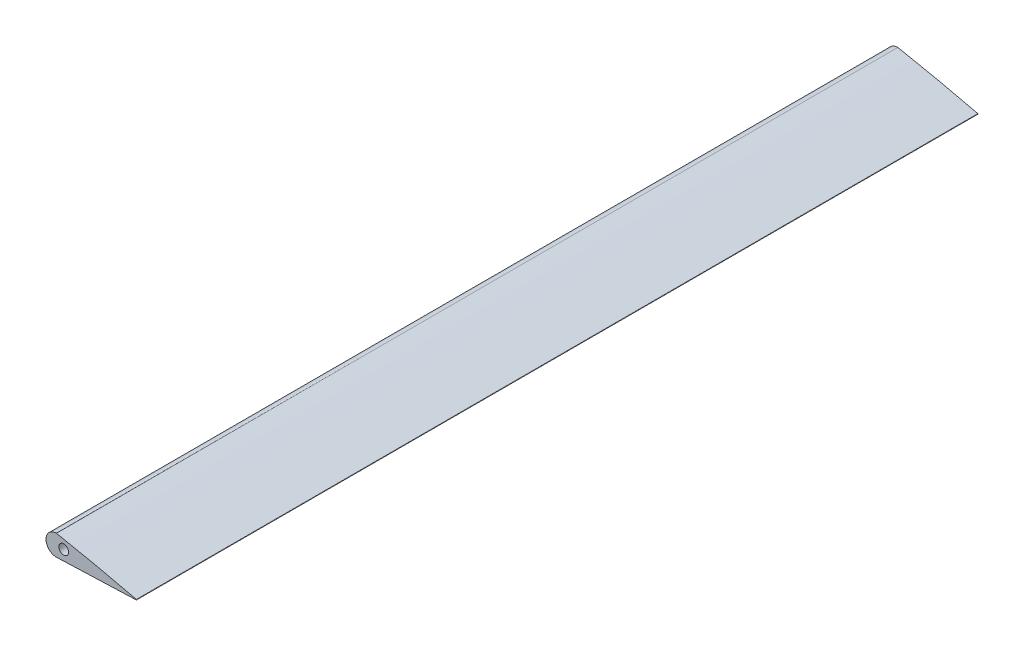
from build123d import *

# Parameters (mm, degrees)
BOSS_EXTRUDE1_DEPTH     = 1246.6
SKETCH3_W               = 131.331770321
SKETCH3_H               = 32.627886165
CUT_EXTRUDE1_DEPTH      = 1246.6
SKETCH4_OUTSIDE_W       = 284.212
SKETCH4_OUTSIDE_H       = 1498.012
SKETCH4_OUTSIDE_W_2     = 101.260819251
SKETCH4_OUTSIDE_H_2     = 902.35
CUT_EXTRUDE2_DEPTH      = 1246.6
CUT_EXTRUDE2_DEPTH_BACK = 1246.6
SKETCH6_W               = 192.425220297
SKETCH6_H               = 656.595980709
CUT_EXTRUDE4_DEPTH      = 244.6
CUT_EXTRUDE4_DEPTH_BACK = 244.6
BOSS_EXTRUDE2_DEPTH     = 344.25
SKETCH8_R               = 2
CUT_EXTRUDE5_DEPTH      = 440.25
BOSS_EXTRUDE3_DEPTH     = 344.25


with BuildPart() as part:
    # Sketch2 → Boss-Extrude1 (new body)
    with BuildSketch(Plane.XY):
        with BuildLine():
            ThreePointArc((164, 0.098236), (164.077666621, 0), (164, -0.098236))
            add(Edge.make_bspline(
                [(164, 0.098236), (163.453347387, 0.22785535), (162.360115672, 0.487076621), (160.720174081, 0.874802791), (159.0803353, 1.261113511), (156.894331896, 1.771896592), (154.161962419, 2.401008024), (150.881840501, 3.13752569), (147.601664878, 3.8565945), (144.321701501, 4.559852267), (141.041699291, 5.246218097), (137.76175682, 5.915571977), (134.481686048, 6.566534279), (131.201761117, 7.199897784), (127.921667908, 7.813753566), (124.641700877, 8.409171836), (121.361597548, 8.984649762), (118.081600921, 9.541284352), (114.80156054, 10.07805903), (111.521600724, 10.59503458), (108.241713881, 11.090964684), (104.961715387, 11.562926189), (101.681785545, 12.010166942), (98.401746925, 12.429708933), (95.121663003, 12.820499879), (91.84154242, 13.181831195), (88.56141358, 13.513629691), (85.281283013, 13.815893693), (82.001169218, 14.088694548), (78.721094583, 14.331740841), (75.441021202, 14.543174526), (72.160894943, 14.719912929), (68.880725837, 14.859427859), (65.600502918, 14.959161187), (62.320224888, 15.016118491), (59.039990485, 15.033011113), (55.759814901, 15.012803506), (52.479681447, 14.959633887), (49.199602023, 14.875645385), (45.919233047, 14.766824698), (42.638537604, 14.618826672), (39.35741618, 14.416022628), (36.0757975, 14.141603361), (32.793533639, 13.779735578), (29.511749086, 13.311848817), (26.230434788, 12.73694115), (22.948210639, 12.059086716), (19.663974378, 11.271431309), (16.378115428, 10.351737997), (13.092739035, 9.271649911), (10.358155698, 8.239855905), (8.178743414, 7.269152702), (6.527119207, 6.423628718), (4.860632605, 5.419014553), (3.322167842, 4.2467282), (2.166779904, 3.134218531), (1.284843627, 2.240038349), (0.724778476, 1.586326252), (0.356487216, 1.023714566), (0.176338644, 0.655158851), (0.06126114, 0.337632955), (-0.042912187, -0.121140297), (0.010077209, -0.598533271), (0.176198668, -1.014077877), (0.354673422, -1.344525075), (0.71711018, -1.826240306), (1.269772602, -2.336774849), (2.131753938, -2.920204414), (3.354944478, -3.392789107), (4.915318485, -3.707166706), (6.554156477, -4.033049695), (8.195338778, -4.283515671), (10.382269573, -4.515400478), (13.118624925, -4.672653042), (16.398857973, -4.828475576), (19.67949402, -4.922126922), (22.959843945, -4.966534444), (26.240094921, -4.967885333), (29.52021808, -4.932840584), (32.80025799, -4.868949356), (36.080251417, -4.782671539), (39.360205991, -4.679002025), (42.640130231, -4.562992137), (45.920050783, -4.439945198), (49.199963424, -4.314095857), (52.479955348, -4.190748674), (55.759981202, -4.070022155), (59.039983191, -3.950079723), (62.320004382, -3.831269928), (65.600009186, -3.712064205), (68.88000861, -3.592327441), (72.160010289, -3.472160061), (75.439998328, -3.351294551), (78.720004422, -3.230701442), (81.999996044, -3.109715239), (85.279997332, -2.98904612), (88.559996558, -2.868484945), (91.840000392, -2.748158688), (95.119999867, -2.627768375), (98.40000014, -2.507399813), (101.679999573, -2.387008373), (104.960003573, -2.266686622), (108.24000017, -2.146108622), (111.519995748, -2.025502888), (114.800004809, -1.905264268), (118.079995042, -1.784567671), (121.360004998, -1.664353418), (124.639994992, -1.543650291), (127.920005011, -1.423437787), (131.199994988, -1.302734192), (134.480005012, -1.182521815), (137.759994988, -1.061818182), (141.040005013, -0.941605825), (144.319994986, -0.820902151), (147.600005017, -0.70068994), (150.879994971, -0.579985719), (154.160005076, -0.45977555), (156.893330138, -0.359182339), (159.080000325, -0.278972842), (160.719999512, -0.218762724), (162.360003633, -0.15863219), (163.453333876, -0.118368088), (164, -0.098236)],
                knots=[0, 0, 0, 0, 0.005027835, 0.010054994, 0.01508103, 0.020105055, 0.030145261, 0.040173646, 0.050190794, 0.06019768, 0.070194226, 0.080180377, 0.09015591, 0.100121106, 0.110075703, 0.120020101, 0.129954271, 0.139878706, 0.149793491, 0.159698811, 0.169594433, 0.179479778, 0.189354744, 0.199219015, 0.209072795, 0.218916603, 0.228751158, 0.238577242, 0.248395636, 0.258207018, 0.268011852, 0.277810604, 0.287604023, 0.297393127, 0.307179253, 0.316964018, 0.326748819, 0.336534715, 0.346322474, 0.356112722, 0.365907652, 0.375711463, 0.385530879, 0.395375762, 0.405259305, 0.415192461, 0.425184025, 0.435248335, 0.445412191, 0.455710779, 0.466190959, 0.471552192, 0.477054504, 0.482786727, 0.488945835, 0.494316033, 0.497126416, 0.500187368, 0.502000869, 0.503128202, 0.503849971, 0.505020137, 0.507317905, 0.507986558, 0.509023586, 0.510668219, 0.513358348, 0.515715812, 0.519949385, 0.524973188, 0.5299544, 0.534903202, 0.539824123, 0.549630394, 0.559425369, 0.569214167, 0.578999733, 0.588784364, 0.598569511, 0.608355933, 0.61814388, 0.627933315, 0.637723968, 0.6475154, 0.657307127, 0.667098669, 0.676889956, 0.686681117, 0.69647219, 0.70626328, 0.716054423, 0.72584562, 0.735636871, 0.745428122, 0.755219391, 0.765010642, 0.774801875, 0.78459309, 0.794384305, 0.80417552, 0.813966735, 0.82375795, 0.833549183, 0.843340416, 0.853131631, 0.862922864, 0.872714079, 0.882505312, 0.892296527, 0.90208776, 0.911878975, 0.921670208, 0.931461423, 0.941252656, 0.951043871, 0.960835104, 0.970626319, 0.980417552, 0.98531316, 0.990208767, 0.995104375, 1, 1, 1, 1], degree=3))
        make_face()
    extrude(amount=BOSS_EXTRUDE1_DEPTH)

    # Sketch3 → Cut-Extrude1 (cut)
    with BuildSketch(Plane.XY.offset(1246.6)):
        with Locations((65.61178146, 9.808584216)):
            Rectangle(SKETCH3_W, SKETCH3_H)
    extrude(amount=-CUT_EXTRUDE1_DEPTH, mode=Mode.SUBTRACT)

    # Sketch4 outside → Cut-Extrude2 (cut, two sides)
    with BuildSketch(Plane(origin=(0, 0, 0), x_dir=(1, 0, 0), z_dir=(0, 1, 0))) as cut_extrude2_sk:
        with Locations((147.678, -623.3)):
            Rectangle(SKETCH4_OUTSIDE_W, SKETCH4_OUTSIDE_H)
        with Locations((113.369590375, -451.175)):
            Rectangle(SKETCH4_OUTSIDE_W_2, SKETCH4_OUTSIDE_H_2, mode=Mode.SUBTRACT)
    extrude(amount=CUT_EXTRUDE2_DEPTH, mode=Mode.SUBTRACT)
    extrude(cut_extrude2_sk.sketch, amount=-CUT_EXTRUDE2_DEPTH_BACK, mode=Mode.SUBTRACT)

    # Sketch6 → Cut-Extrude4 (cut, two sides)
    with BuildSketch(Plane(origin=(0, 0, 0), x_dir=(1, 0, 0), z_dir=(0, 1, 0))) as cut_extrude4_sk:
        with Locations((81.978543906, -672.547990355)):
            Rectangle(SKETCH6_W, SKETCH6_H)
    extrude(amount=CUT_EXTRUDE4_DEPTH, mode=Mode.SUBTRACT)
    extrude(cut_extrude4_sk.sketch, amount=-CUT_EXTRUDE4_DEPTH_BACK, mode=Mode.SUBTRACT)

    # Sketch7 → Boss-Extrude2 (add)
    with BuildSketch(Plane(origin=(0, 0, 0), x_dir=(-1, 0, 0), z_dir=(0, 0, -1))):
        with BuildLine():
            Line((-164, 0.098236), (-164, -0.098236))
            add(Edge.make_bspline(
                [(-164, -0.098236), (-163.453333876, -0.118368088), (-162.360003633, -0.15863219), (-160.719999512, -0.218762724), (-159.080000325, -0.278972842), (-156.893330138, -0.359182339), (-154.160005076, -0.45977555), (-150.879994971, -0.579985719), (-147.600005017, -0.70068994), (-144.319994986, -0.820902151), (-141.040005013, -0.941605825), (-137.759994988, -1.061818182), (-134.505893813, -1.181569107), (-132.345110216, -1.260765669), (-131.277666621, -1.299963829)],
                knots=[0.902319605, 0.902319605, 0.902319605, 0.902319605, 0.90721523, 0.912110838, 0.917006445, 0.921902053, 0.931693286, 0.941484501, 0.951275734, 0.961066949, 0.970858182, 0.980649397, 0.99044063, 1, 1, 1, 1], degree=3))
            ThreePointArc((-131.277666621, -1.299963829), (-127.036582482, 2.94112032), (-131.27766664, 7.182204449))
            add(Edge.make_bspline(
                [(-131.27766664, 7.182204449), (-132.345665951, 6.979004635), (-134.50753497, 6.561404307), (-137.76175682, 5.915571977), (-141.041699291, 5.246218097), (-144.321701501, 4.559852267), (-147.601664878, 3.8565945), (-150.881840501, 3.13752569), (-154.161962419, 2.401008024), (-156.894331896, 1.771896592), (-159.0803353, 1.261113511), (-160.720174081, 0.874802791), (-162.360115672, 0.487076621), (-163.453347387, 0.22785535), (-164, 0.098236)],
                knots=[0, 0, 0, 0, 0.009729354, 0.019704887, 0.029691038, 0.039687584, 0.04969447, 0.059711618, 0.069740003, 0.079780209, 0.084804234, 0.08983027, 0.094857429, 0.099885264, 0.099885264, 0.099885264, 0.099885264], degree=3))
        make_face()
    extrude(amount=-BOSS_EXTRUDE2_DEPTH)

    # Sketch8 → Cut-Extrude5 (cut)
    with BuildSketch(Plane(origin=(0, 0, 0), x_dir=(-1, 0, 0), z_dir=(0, 0, -1))):
        with Locations((-134.27766664, 2.94112031)):
            Circle(SKETCH8_R)
    extrude(amount=-CUT_EXTRUDE5_DEPTH, mode=Mode.SUBTRACT)

    # Sketch9 → Boss-Extrude3 (add)
    with BuildSketch(Plane(origin=(0, 0, 0), x_dir=(-1, 0, 0), z_dir=(0, 0, -1))):
        with BuildLine():
            Line((-164, 0.098236), (-164, -0.098236))
            ThreePointArc((-164, -0.098236), (-164.077666649, 0), (-164, 0.098236))
        make_face()
    extrude(amount=-BOSS_EXTRUDE3_DEPTH)


solid = part.part
